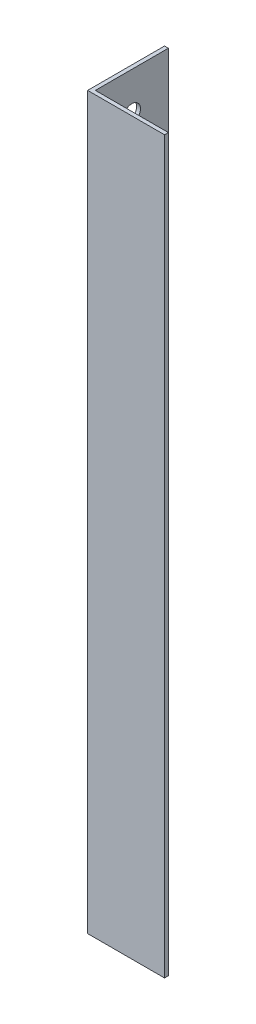
from build123d import *

# Parameters (mm, degrees)
EXTRUDE_1_DEPTH     = 190
SKETCH_2_R          = 2.25
CUT_EXTRUDE_1_DEPTH = 2
SKETCH_3_R          = 2.25
CUT_EXTRUDE_2_DEPTH = 21


with BuildPart() as part:
    # Эскиз1 → Бобышка-Вытянуть1 (new body)
    with BuildSketch(Plane(origin=(0, 0, 0), x_dir=(1, 0, 0), z_dir=(0, 1, 0))):
        Polygon((0, 0), (0, 20), (1, 20), (1, 1), (20, 1), (20, 0), align=None)
    extrude(amount=EXTRUDE_1_DEPTH)

    # Эскиз2 → Вырез-Вытянуть1 (cut, through all)
    with BuildSketch(Plane(origin=(1, 0, 0), x_dir=(0, 0, -1), z_dir=(1, 0, 0))):
        with Locations((10.5, 10)):
            Circle(SKETCH_2_R)
        with Locations((10.5, 180)):
            Circle(SKETCH_2_R)
    extrude(amount=-CUT_EXTRUDE_1_DEPTH, mode=Mode.SUBTRACT)

    # Эскиз3 → Вырез-Вытянуть2 (cut, through all)
    with BuildSketch(Plane.ZY):
        with Locations((-10.5, 159.5)):
            Circle(SKETCH_3_R)
    extrude(amount=-CUT_EXTRUDE_2_DEPTH, mode=Mode.SUBTRACT)


solid = part.part
